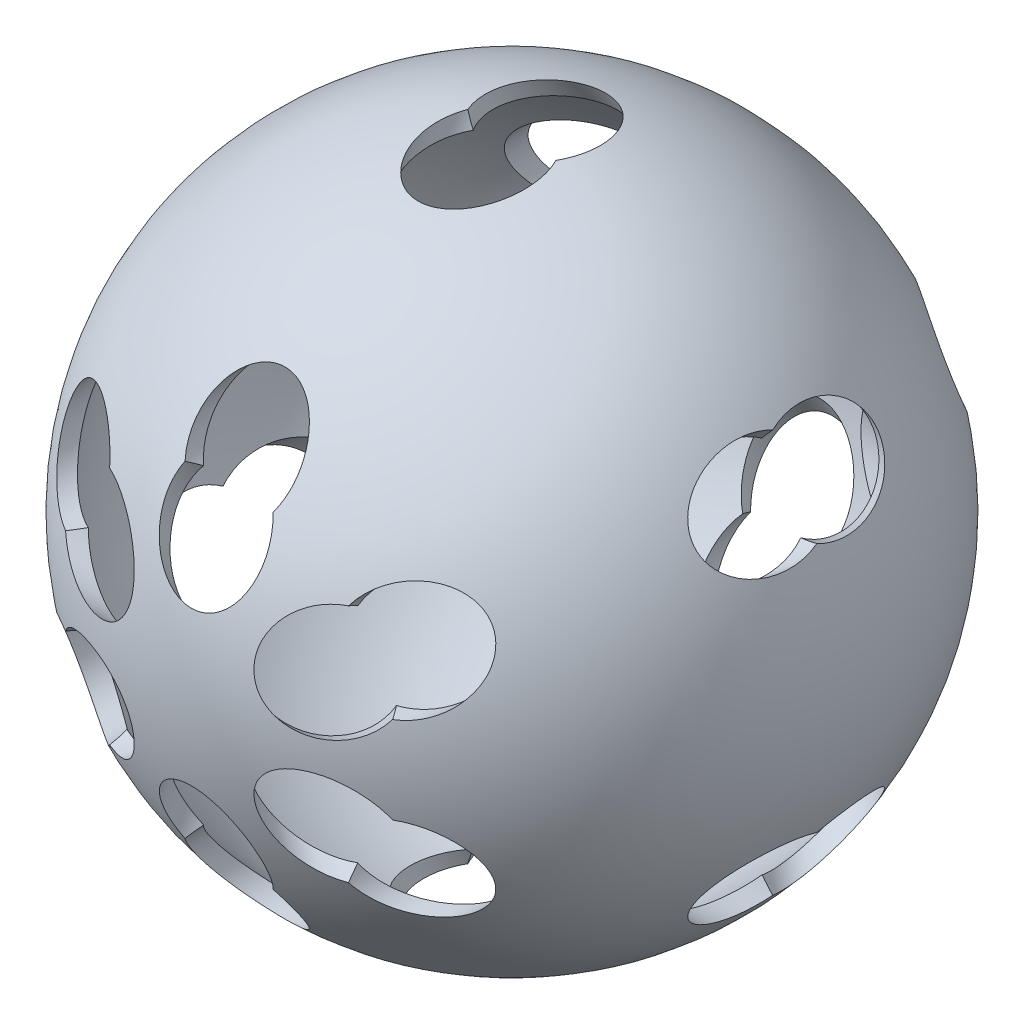
from build123d import *

# Parameters (mm, degrees)
SKETCH2_R                     = 9.525
CUT_EXTRUDE1_DEPTH            = 62.9125
CIRPATTERN29_COUNT            = 6
CIRPATTERN30_COUNT            = 6
CIRPATTERN30_COPY_1_SKETCH_R  = 9.525
CIRPATTERN30_COPY_1_DEPTH     = 62.9125
CIRPATTERN30_COPY_2_SKETCH_R  = 9.525
CIRPATTERN30_COPY_2_DEPTH     = 62.9125
CIRPATTERN30_COPY_3_SKETCH_R  = 9.525
CIRPATTERN30_COPY_3_DEPTH     = 62.9125
CIRPATTERN30_COPY_4_SKETCH_R  = 9.525
CIRPATTERN30_COPY_4_DEPTH     = 62.9125
CIRPATTERN30_COPY_5_SKETCH_R  = 9.525
CIRPATTERN30_COPY_5_DEPTH     = 62.9125
CIRPATTERN30_COPY_6_SKETCH_R  = 9.525
CIRPATTERN30_COPY_6_DEPTH     = 62.9125
CIRPATTERN30_COPY_7_SKETCH_R  = 9.525
CIRPATTERN30_COPY_7_DEPTH     = 62.9125
CIRPATTERN30_COPY_8_SKETCH_R  = 9.525
CIRPATTERN30_COPY_8_DEPTH     = 62.9125
CIRPATTERN30_COPY_9_SKETCH_R  = 9.525
CIRPATTERN30_COPY_9_DEPTH     = 62.9125
CIRPATTERN30_COPY_10_SKETCH_R = 9.525
CIRPATTERN30_COPY_10_DEPTH    = 62.9125
CIRPATTERN30_COPY_11_SKETCH_R = 9.525
CIRPATTERN30_COPY_11_DEPTH    = 62.9125
CIRPATTERN30_COPY_12_SKETCH_R = 9.525
CIRPATTERN30_COPY_12_DEPTH    = 62.9125
CIRPATTERN30_COPY_13_SKETCH_R = 9.525
CIRPATTERN30_COPY_13_DEPTH    = 62.9125
CIRPATTERN30_COPY_14_SKETCH_R = 9.525
CIRPATTERN30_COPY_14_DEPTH    = 62.9125
CIRPATTERN30_COPY_15_SKETCH_R = 9.525
CIRPATTERN30_COPY_15_DEPTH    = 62.9125
CIRPATTERN30_COPY_16_SKETCH_R = 9.525
CIRPATTERN30_COPY_16_DEPTH    = 62.9125
CIRPATTERN30_COPY_17_SKETCH_R = 9.525
CIRPATTERN30_COPY_17_DEPTH    = 62.9125
CIRPATTERN30_COPY_18_SKETCH_R = 9.525
CIRPATTERN30_COPY_18_DEPTH    = 62.9125
CIRPATTERN30_COPY_19_SKETCH_R = 9.525
CIRPATTERN30_COPY_19_DEPTH    = 62.9125
CIRPATTERN30_COPY_20_SKETCH_R = 9.525
CIRPATTERN30_COPY_20_DEPTH    = 62.9125
CIRPATTERN30_COPY_21_SKETCH_R = 9.525
CIRPATTERN30_COPY_21_DEPTH    = 62.9125
CIRPATTERN30_COPY_22_SKETCH_R = 9.525
CIRPATTERN30_COPY_22_DEPTH    = 62.9125
CIRPATTERN30_COPY_23_SKETCH_R = 9.525
CIRPATTERN30_COPY_23_DEPTH    = 62.9125
CIRPATTERN30_COPY_24_SKETCH_R = 9.525
CIRPATTERN30_COPY_24_DEPTH    = 62.9125
CIRPATTERN30_COPY_25_SKETCH_R = 9.525
CIRPATTERN30_COPY_25_DEPTH    = 62.9125


with BuildPart() as part:
    # Sketch1 → Revolve-Thin1 (revolve)
    with BuildSketch(Plane.XY):
        with BuildLine():
            ThreePointArc((0, 61.9125), (61.9125, 0), (0, -61.9125))
            Line((0, -61.9125), (0, -58.9125))
            ThreePointArc((0, -58.9125), (58.9125, 0), (0, 58.9125))
            Line((0, 58.9125), (0, 61.9125))
        make_face()
    revolve(axis=Axis((0, 61.9125, 0), (0, -1, 0)))

    # Sketch2 → Cut-Extrude1 (cut, through all)
    with BuildSketch(Plane.XY):
        with Locations((0, 35.390926185)):
            Circle(SKETCH2_R)
    cut_extrude1 = extrude(amount=CUT_EXTRUDE1_DEPTH, mode=Mode.SUBTRACT)

    # CirPattern29: Cut-Extrude1 ×6 about axis
    cirpattern29_axis = Axis((0, 0, 0), (-1, 0, 0))
    for i in range(1, CIRPATTERN29_COUNT):
        add(cut_extrude1.rotate(cirpattern29_axis, i * 360 / CIRPATTERN29_COUNT), mode=Mode.SUBTRACT)

    # CirPattern30: Cut-Extrude1 ×6 about axis
    cirpattern30_axis = Axis((0, 0, 0), (0, 0, 1))
    for i in range(1, CIRPATTERN30_COUNT):
        add(cut_extrude1.rotate(cirpattern30_axis, i * 360 / CIRPATTERN30_COUNT), mode=Mode.SUBTRACT)

    # CirPattern30 copy 1 sketch → CirPattern30 copy 1 (cut, through all)
    with BuildSketch(Plane(origin=(0, 0, 0), x_dir=(0.5, 0.866025404, 0), z_dir=(-0.75, 0.433012702, 0.5))):
        with Locations((0, 35.390926185)):
            Circle(CIRPATTERN30_COPY_1_SKETCH_R)
    extrude(amount=CIRPATTERN30_COPY_1_DEPTH, mode=Mode.SUBTRACT)

    # CirPattern30 copy 2 sketch → CirPattern30 copy 2 (cut, through all)
    with BuildSketch(Plane(origin=(0, 0, 0), x_dir=(-0.5, 0.866025404, 0), z_dir=(-0.75, -0.433012702, 0.5))):
        with Locations((0, 35.390926185)):
            Circle(CIRPATTERN30_COPY_2_SKETCH_R)
    extrude(amount=CIRPATTERN30_COPY_2_DEPTH, mode=Mode.SUBTRACT)

    # CirPattern30 copy 3 sketch → CirPattern30 copy 3 (cut, through all)
    with BuildSketch(Plane(origin=(0, 0, 0), x_dir=(-1, 0, 0), z_dir=(0, -0.866025404, 0.5))):
        with Locations((0, 35.390926185)):
            Circle(CIRPATTERN30_COPY_3_SKETCH_R)
    extrude(amount=CIRPATTERN30_COPY_3_DEPTH, mode=Mode.SUBTRACT)

    # CirPattern30 copy 4 sketch → CirPattern30 copy 4 (cut, through all)
    with BuildSketch(Plane(origin=(0, 0, 0), x_dir=(-0.5, -0.866025404, 0), z_dir=(0.75, -0.433012702, 0.5))):
        with Locations((0, 35.390926185)):
            Circle(CIRPATTERN30_COPY_4_SKETCH_R)
    extrude(amount=CIRPATTERN30_COPY_4_DEPTH, mode=Mode.SUBTRACT)

    # CirPattern30 copy 5 sketch → CirPattern30 copy 5 (cut, through all)
    with BuildSketch(Plane(origin=(0, 0, 0), x_dir=(0.5, -0.866025404, 0), z_dir=(0.75, 0.433012702, 0.5))):
        with Locations((0, 35.390926185)):
            Circle(CIRPATTERN30_COPY_5_SKETCH_R)
    extrude(amount=CIRPATTERN30_COPY_5_DEPTH, mode=Mode.SUBTRACT)

    # CirPattern30 copy 6 sketch → CirPattern30 copy 6 (cut, through all)
    with BuildSketch(Plane(origin=(0, 0, 0), x_dir=(0.5, 0.866025404, 0), z_dir=(-0.75, 0.433012702, -0.5))):
        with Locations((0, 35.390926185)):
            Circle(CIRPATTERN30_COPY_6_SKETCH_R)
    extrude(amount=CIRPATTERN30_COPY_6_DEPTH, mode=Mode.SUBTRACT)

    # CirPattern30 copy 7 sketch → CirPattern30 copy 7 (cut, through all)
    with BuildSketch(Plane(origin=(0, 0, 0), x_dir=(-0.5, 0.866025404, 0), z_dir=(-0.75, -0.433012702, -0.5))):
        with Locations((0, 35.390926185)):
            Circle(CIRPATTERN30_COPY_7_SKETCH_R)
    extrude(amount=CIRPATTERN30_COPY_7_DEPTH, mode=Mode.SUBTRACT)

    # CirPattern30 copy 8 sketch → CirPattern30 copy 8 (cut, through all)
    with BuildSketch(Plane(origin=(0, 0, 0), x_dir=(-1, 0, 0), z_dir=(0, -0.866025404, -0.5))):
        with Locations((0, 35.390926185)):
            Circle(CIRPATTERN30_COPY_8_SKETCH_R)
    extrude(amount=CIRPATTERN30_COPY_8_DEPTH, mode=Mode.SUBTRACT)

    # CirPattern30 copy 9 sketch → CirPattern30 copy 9 (cut, through all)
    with BuildSketch(Plane(origin=(0, 0, 0), x_dir=(-0.5, -0.866025404, 0), z_dir=(0.75, -0.433012702, -0.5))):
        with Locations((0, 35.390926185)):
            Circle(CIRPATTERN30_COPY_9_SKETCH_R)
    extrude(amount=CIRPATTERN30_COPY_9_DEPTH, mode=Mode.SUBTRACT)

    # CirPattern30 copy 10 sketch → CirPattern30 copy 10 (cut, through all)
    with BuildSketch(Plane(origin=(0, 0, 0), x_dir=(0.5, -0.866025404, 0), z_dir=(0.75, 0.433012702, -0.5))):
        with Locations((0, 35.390926185)):
            Circle(CIRPATTERN30_COPY_10_SKETCH_R)
    extrude(amount=CIRPATTERN30_COPY_10_DEPTH, mode=Mode.SUBTRACT)

    # CirPattern30 copy 11 sketch → CirPattern30 copy 11 (cut, through all)
    with BuildSketch(Plane(origin=(0, 0, 0), x_dir=(0.5, 0.866025404, 0), z_dir=(0, 0, -1))):
        with Locations((0, 35.390926185)):
            Circle(CIRPATTERN30_COPY_11_SKETCH_R)
    extrude(amount=CIRPATTERN30_COPY_11_DEPTH, mode=Mode.SUBTRACT)

    # CirPattern30 copy 12 sketch → CirPattern30 copy 12 (cut, through all)
    with BuildSketch(Plane(origin=(0, 0, 0), x_dir=(-0.5, 0.866025404, 0), z_dir=(0, 0, -1))):
        with Locations((0, 35.390926185)):
            Circle(CIRPATTERN30_COPY_12_SKETCH_R)
    extrude(amount=CIRPATTERN30_COPY_12_DEPTH, mode=Mode.SUBTRACT)

    # CirPattern30 copy 13 sketch → CirPattern30 copy 13 (cut, through all)
    with BuildSketch(Plane(origin=(0, 0, 0), x_dir=(-1, 0, 0), z_dir=(0, 0, -1))):
        with Locations((0, 35.390926185)):
            Circle(CIRPATTERN30_COPY_13_SKETCH_R)
    extrude(amount=CIRPATTERN30_COPY_13_DEPTH, mode=Mode.SUBTRACT)

    # CirPattern30 copy 14 sketch → CirPattern30 copy 14 (cut, through all)
    with BuildSketch(Plane(origin=(0, 0, 0), x_dir=(-0.5, -0.866025404, 0), z_dir=(0, 0, -1))):
        with Locations((0, 35.390926185)):
            Circle(CIRPATTERN30_COPY_14_SKETCH_R)
    extrude(amount=CIRPATTERN30_COPY_14_DEPTH, mode=Mode.SUBTRACT)

    # CirPattern30 copy 15 sketch → CirPattern30 copy 15 (cut, through all)
    with BuildSketch(Plane(origin=(0, 0, 0), x_dir=(0.5, -0.866025404, 0), z_dir=(0, 0, -1))):
        with Locations((0, 35.390926185)):
            Circle(CIRPATTERN30_COPY_15_SKETCH_R)
    extrude(amount=CIRPATTERN30_COPY_15_DEPTH, mode=Mode.SUBTRACT)

    # CirPattern30 copy 16 sketch → CirPattern30 copy 16 (cut, through all)
    with BuildSketch(Plane(origin=(0, 0, 0), x_dir=(0.5, 0.866025404, 0), z_dir=(0.75, -0.433012702, -0.5))):
        with Locations((0, 35.390926185)):
            Circle(CIRPATTERN30_COPY_16_SKETCH_R)
    extrude(amount=CIRPATTERN30_COPY_16_DEPTH, mode=Mode.SUBTRACT)

    # CirPattern30 copy 17 sketch → CirPattern30 copy 17 (cut, through all)
    with BuildSketch(Plane(origin=(0, 0, 0), x_dir=(-0.5, 0.866025404, 0), z_dir=(0.75, 0.433012702, -0.5))):
        with Locations((0, 35.390926185)):
            Circle(CIRPATTERN30_COPY_17_SKETCH_R)
    extrude(amount=CIRPATTERN30_COPY_17_DEPTH, mode=Mode.SUBTRACT)

    # CirPattern30 copy 18 sketch → CirPattern30 copy 18 (cut, through all)
    with BuildSketch(Plane(origin=(0, 0, 0), x_dir=(-1, 0, 0), z_dir=(0, 0.866025404, -0.5))):
        with Locations((0, 35.390926185)):
            Circle(CIRPATTERN30_COPY_18_SKETCH_R)
    extrude(amount=CIRPATTERN30_COPY_18_DEPTH, mode=Mode.SUBTRACT)

    # CirPattern30 copy 19 sketch → CirPattern30 copy 19 (cut, through all)
    with BuildSketch(Plane(origin=(0, 0, 0), x_dir=(-0.5, -0.866025404, 0), z_dir=(-0.75, 0.433012702, -0.5))):
        with Locations((0, 35.390926185)):
            Circle(CIRPATTERN30_COPY_19_SKETCH_R)
    extrude(amount=CIRPATTERN30_COPY_19_DEPTH, mode=Mode.SUBTRACT)

    # CirPattern30 copy 20 sketch → CirPattern30 copy 20 (cut, through all)
    with BuildSketch(Plane(origin=(0, 0, 0), x_dir=(0.5, -0.866025404, 0), z_dir=(-0.75, -0.433012702, -0.5))):
        with Locations((0, 35.390926185)):
            Circle(CIRPATTERN30_COPY_20_SKETCH_R)
    extrude(amount=CIRPATTERN30_COPY_20_DEPTH, mode=Mode.SUBTRACT)

    # CirPattern30 copy 21 sketch → CirPattern30 copy 21 (cut, through all)
    with BuildSketch(Plane(origin=(0, 0, 0), x_dir=(0.5, 0.866025404, 0), z_dir=(0.75, -0.433012702, 0.5))):
        with Locations((0, 35.390926185)):
            Circle(CIRPATTERN30_COPY_21_SKETCH_R)
    extrude(amount=CIRPATTERN30_COPY_21_DEPTH, mode=Mode.SUBTRACT)

    # CirPattern30 copy 22 sketch → CirPattern30 copy 22 (cut, through all)
    with BuildSketch(Plane(origin=(0, 0, 0), x_dir=(-0.5, 0.866025404, 0), z_dir=(0.75, 0.433012702, 0.5))):
        with Locations((0, 35.390926185)):
            Circle(CIRPATTERN30_COPY_22_SKETCH_R)
    extrude(amount=CIRPATTERN30_COPY_22_DEPTH, mode=Mode.SUBTRACT)

    # CirPattern30 copy 23 sketch → CirPattern30 copy 23 (cut, through all)
    with BuildSketch(Plane(origin=(0, 0, 0), x_dir=(-1, 0, 0), z_dir=(0, 0.866025404, 0.5))):
        with Locations((0, 35.390926185)):
            Circle(CIRPATTERN30_COPY_23_SKETCH_R)
    extrude(amount=CIRPATTERN30_COPY_23_DEPTH, mode=Mode.SUBTRACT)

    # CirPattern30 copy 24 sketch → CirPattern30 copy 24 (cut, through all)
    with BuildSketch(Plane(origin=(0, 0, 0), x_dir=(-0.5, -0.866025404, 0), z_dir=(-0.75, 0.433012702, 0.5))):
        with Locations((0, 35.390926185)):
            Circle(CIRPATTERN30_COPY_24_SKETCH_R)
    extrude(amount=CIRPATTERN30_COPY_24_DEPTH, mode=Mode.SUBTRACT)

    # CirPattern30 copy 25 sketch → CirPattern30 copy 25 (cut, through all)
    with BuildSketch(Plane(origin=(0, 0, 0), x_dir=(0.5, -0.866025404, 0), z_dir=(-0.75, -0.433012702, 0.5))):
        with Locations((0, 35.390926185)):
            Circle(CIRPATTERN30_COPY_25_SKETCH_R)
    extrude(amount=CIRPATTERN30_COPY_25_DEPTH, mode=Mode.SUBTRACT)


solid = part.part
